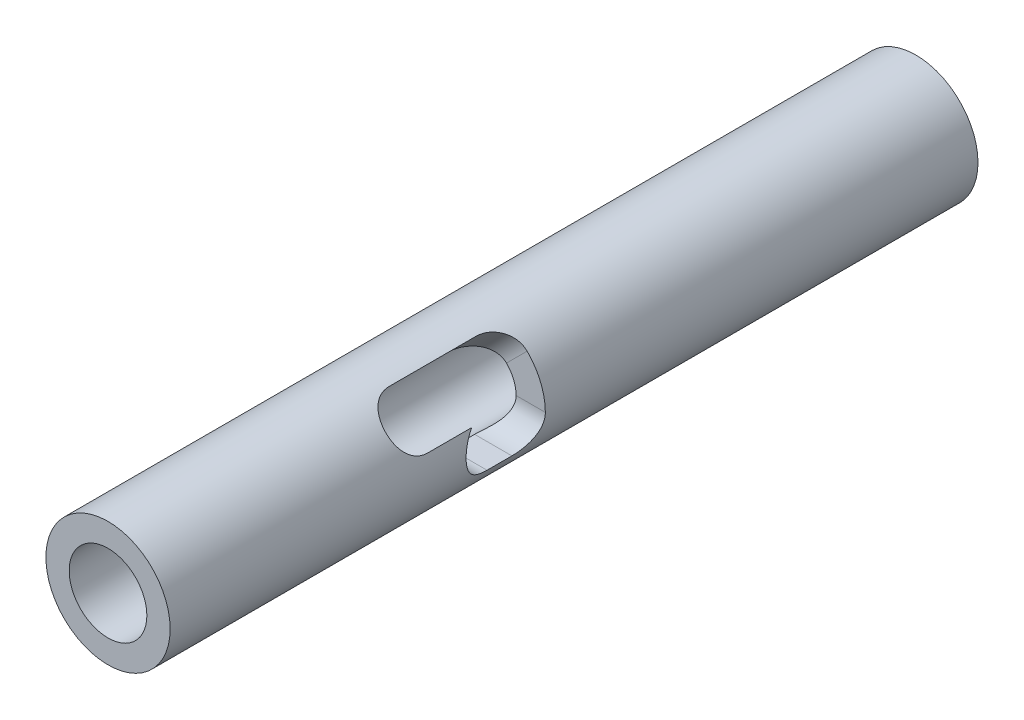
from build123d import *

# Parameters (mm, degrees)
SKETCH1_R                   = 6.35
SKETCH1_R_2                 = 3.3655
BOSS_EXTRUDE1_DEPTH         = 82.55
F_3_8_16_TAPPED_HOLE0_D     = 7.9375
F_3_8_16_TAPPED_HOLE0_DEPTH = 19.05
F_3_8_16_TAPPED_HOLE0_TIP   = 2.384665582
CUT_EXTRUDE2_DEPTH          = 7.35
SKETCH75_W                  = 12.7
SKETCH75_H                  = 5.318125
CUT_REVOLVE1_ANGLE          = 45
CUT_EXTRUDE3_DEPTH          = 9.980256262
F_3_8_16_TAPPED_HOLE1_D     = 7.9375
F_3_8_16_TAPPED_HOLE1_DEPTH = 19.05
F_3_8_16_TAPPED_HOLE1_TIP   = 2.384665582


with BuildPart() as part:
    # Sketch1 → Boss-Extrude1 (new body)
    with BuildSketch(Plane.XY):
        Circle(SKETCH1_R)
        Circle(SKETCH1_R_2, mode=Mode.SUBTRACT)
    extrude(amount=BOSS_EXTRUDE1_DEPTH)

    # 3/8-16 Tapped Hole0
    with Locations(Plane(origin=(0, 0, 0), x_dir=(-1, 0, 0), z_dir=(0, 0, -1))):
        with Locations((0, 0)):
            Hole(F_3_8_16_TAPPED_HOLE0_D / 2, depth=F_3_8_16_TAPPED_HOLE0_DEPTH)
            with Locations((0, 0, -(F_3_8_16_TAPPED_HOLE0_DEPTH + F_3_8_16_TAPPED_HOLE0_TIP / 2))):  # 118° drill point
                Cone(0, F_3_8_16_TAPPED_HOLE0_D / 2, F_3_8_16_TAPPED_HOLE0_TIP, mode=Mode.SUBTRACT)

    # Sketch13 → Cut-Extrude2 (cut, through all)
    with BuildSketch(Plane(origin=(0, 0, 0), x_dir=(0, 0, -1), z_dir=(1, 0, 0))):
        with BuildLine():
            Line((-49.53, 2.778125), (-46.99, 2.778125))
            ThreePointArc((-46.99, 2.778125), (-44.211875, 0), (-46.99, -2.778125))
            Line((-46.99, -2.778125), (-49.53, -2.778125))
            ThreePointArc((-49.53, -2.778125), (-52.308125, 0), (-49.53, 2.778125))
        make_face()
    extrude(amount=CUT_EXTRUDE2_DEPTH, mode=Mode.SUBTRACT)

    # Sketch75 → Cut-Revolve1 (revolve, cut)
    with BuildSketch(Plane(origin=(0, 0, 0), x_dir=(1, 0, 0), z_dir=(0, 1, 0))):
        with Locations((6.35, -46.8709375)):
            Rectangle(SKETCH75_W, SKETCH75_H)
    revolve(axis=Axis((0, 0, 0), (0, 0, 1)), revolution_arc=CUT_REVOLVE1_ANGLE, mode=Mode.SUBTRACT)

    # Sketch52 → Cut-Extrude3 (cut, through all)
    with BuildSketch(Plane(origin=(0, 0, 0), x_dir=(0.707106781, -0.707106781, 0), z_dir=(0.707106781, 0.707106781, 0))):
        with BuildLine():
            Line((-2.778125, -55.88), (-2.778125, -46.99))
            ThreePointArc((-2.778125, -46.99), (0, -44.211875), (2.778125, -46.99))
            Line((2.778125, -46.99), (2.778125, -55.88))
            ThreePointArc((2.778125, -55.88), (0, -58.658125), (-2.778125, -55.88))
        make_face()
    extrude(amount=CUT_EXTRUDE3_DEPTH, mode=Mode.SUBTRACT)

    # 3/8-16 Tapped Hole1
    with Locations(Plane.XY.offset(82.55)):
        with Locations((0, 0)):
            Hole(F_3_8_16_TAPPED_HOLE1_D / 2, depth=F_3_8_16_TAPPED_HOLE1_DEPTH)
            with Locations((0, 0, -(F_3_8_16_TAPPED_HOLE1_DEPTH + F_3_8_16_TAPPED_HOLE1_TIP / 2))):  # 118° drill point
                Cone(0, F_3_8_16_TAPPED_HOLE1_D / 2, F_3_8_16_TAPPED_HOLE1_TIP, mode=Mode.SUBTRACT)


solid = part.part
